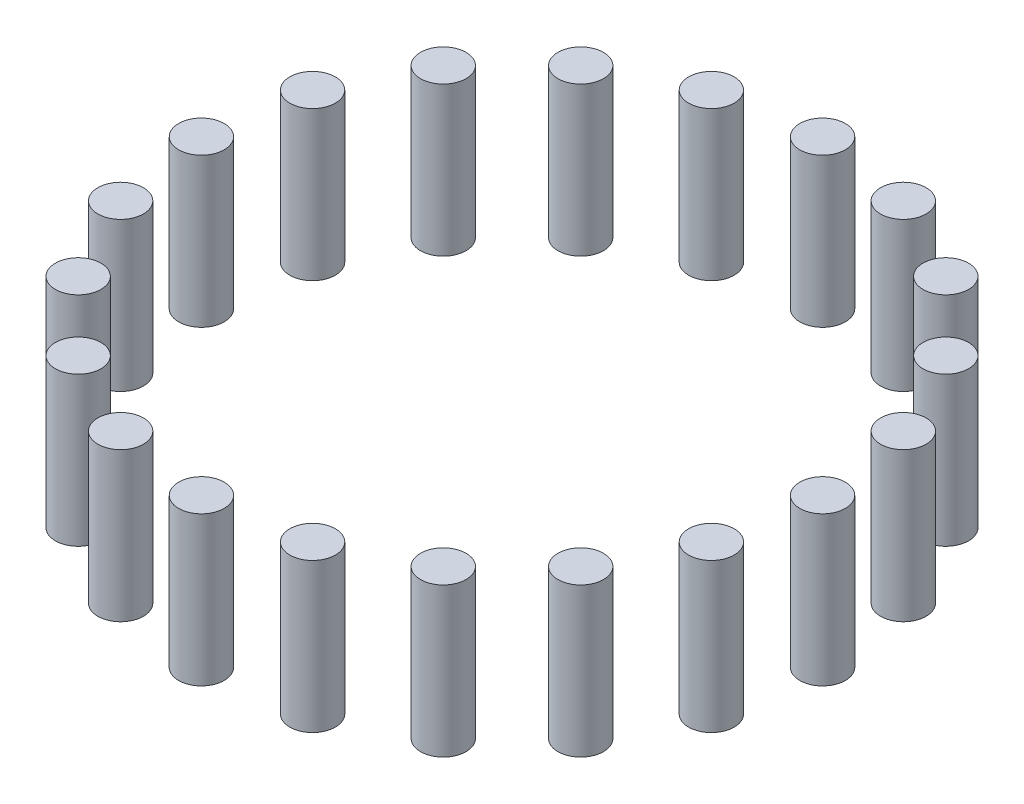
from build123d import *

# Parameters (mm, degrees)
SKETCH1_R              = 5.5
BOSS_EXTRUDE1_DEPTH    = 36
BOSS_EXTRUDE1_2_DEPTH  = 36
BOSS_EXTRUDE1_3_DEPTH  = 36
BOSS_EXTRUDE1_4_DEPTH  = 36
BOSS_EXTRUDE1_5_DEPTH  = 36
BOSS_EXTRUDE1_6_DEPTH  = 36
BOSS_EXTRUDE1_7_DEPTH  = 36
BOSS_EXTRUDE1_8_DEPTH  = 36
BOSS_EXTRUDE1_9_DEPTH  = 36
BOSS_EXTRUDE1_10_DEPTH = 36
BOSS_EXTRUDE1_11_DEPTH = 36
BOSS_EXTRUDE1_12_DEPTH = 36
BOSS_EXTRUDE1_13_DEPTH = 36
BOSS_EXTRUDE1_14_DEPTH = 36
BOSS_EXTRUDE1_15_DEPTH = 36
BOSS_EXTRUDE1_16_DEPTH = 36
BOSS_EXTRUDE1_17_DEPTH = 36
BOSS_EXTRUDE1_18_DEPTH = 36
BOSS_EXTRUDE1_19_DEPTH = 36
BOSS_EXTRUDE1_20_DEPTH = 36


with BuildPart() as part:
    # Sketch1 → Boss-Extrude1 (new body)
    with BuildSketch(Plane(origin=(0, 0, 0), x_dir=(1, 0, 0), z_dir=(0, 1, 0))):
        with Locations((75, 0)):
            Circle(SKETCH1_R)
    extrude(amount=BOSS_EXTRUDE1_DEPTH)


with BuildPart() as body_2:
    # Sketch1 → Boss-Extrude1 2 (new body)
    with BuildSketch(Plane(origin=(0, 0, 0), x_dir=(1, 0, 0), z_dir=(0, 1, 0))):
        with Locations((71.329238722, -23.176274578)):
            Circle(SKETCH1_R)
    extrude(amount=BOSS_EXTRUDE1_2_DEPTH)


with BuildPart() as body_3:
    # Sketch1 → Boss-Extrude1 3 (new body)
    with BuildSketch(Plane(origin=(0, 0, 0), x_dir=(1, 0, 0), z_dir=(0, 1, 0))):
        with Locations((60.676274578, -44.083893922)):
            Circle(SKETCH1_R)
    extrude(amount=BOSS_EXTRUDE1_3_DEPTH)


with BuildPart() as body_4:
    # Sketch1 → Boss-Extrude1 4 (new body)
    with BuildSketch(Plane(origin=(0, 0, 0), x_dir=(1, 0, 0), z_dir=(0, 1, 0))):
        with Locations((44.083893922, -60.676274578)):
            Circle(SKETCH1_R)
    extrude(amount=BOSS_EXTRUDE1_4_DEPTH)


with BuildPart() as body_5:
    # Sketch1 → Boss-Extrude1 5 (new body)
    with BuildSketch(Plane(origin=(0, 0, 0), x_dir=(1, 0, 0), z_dir=(0, 1, 0))):
        with Locations((23.176274578, -71.329238722)):
            Circle(SKETCH1_R)
    extrude(amount=BOSS_EXTRUDE1_5_DEPTH)


with BuildPart() as body_6:
    # Sketch1 → Boss-Extrude1 6 (new body)
    with BuildSketch(Plane(origin=(0, 0, 0), x_dir=(1, 0, 0), z_dir=(0, 1, 0))):
        with Locations((0, -75)):
            Circle(SKETCH1_R)
    extrude(amount=BOSS_EXTRUDE1_6_DEPTH)


with BuildPart() as body_7:
    # Sketch1 → Boss-Extrude1 7 (new body)
    with BuildSketch(Plane(origin=(0, 0, 0), x_dir=(1, 0, 0), z_dir=(0, 1, 0))):
        with Locations((-23.176274578, -71.329238722)):
            Circle(SKETCH1_R)
    extrude(amount=BOSS_EXTRUDE1_7_DEPTH)


with BuildPart() as body_8:
    # Sketch1 → Boss-Extrude1 8 (new body)
    with BuildSketch(Plane(origin=(0, 0, 0), x_dir=(1, 0, 0), z_dir=(0, 1, 0))):
        with Locations((-44.083893922, -60.676274578)):
            Circle(SKETCH1_R)
    extrude(amount=BOSS_EXTRUDE1_8_DEPTH)


with BuildPart() as body_9:
    # Sketch1 → Boss-Extrude1 9 (new body)
    with BuildSketch(Plane(origin=(0, 0, 0), x_dir=(1, 0, 0), z_dir=(0, 1, 0))):
        with Locations((-60.676274578, -44.083893922)):
            Circle(SKETCH1_R)
    extrude(amount=BOSS_EXTRUDE1_9_DEPTH)


with BuildPart() as body_10:
    # Sketch1 → Boss-Extrude1 10 (new body)
    with BuildSketch(Plane(origin=(0, 0, 0), x_dir=(1, 0, 0), z_dir=(0, 1, 0))):
        with Locations((-71.329238722, -23.176274578)):
            Circle(SKETCH1_R)
    extrude(amount=BOSS_EXTRUDE1_10_DEPTH)


with BuildPart() as body_11:
    # Sketch1 → Boss-Extrude1 11 (new body)
    with BuildSketch(Plane(origin=(0, 0, 0), x_dir=(1, 0, 0), z_dir=(0, 1, 0))):
        with Locations((-75, 0)):
            Circle(SKETCH1_R)
    extrude(amount=BOSS_EXTRUDE1_11_DEPTH)


with BuildPart() as body_12:
    # Sketch1 → Boss-Extrude1 12 (new body)
    with BuildSketch(Plane(origin=(0, 0, 0), x_dir=(1, 0, 0), z_dir=(0, 1, 0))):
        with Locations((-71.329238722, 23.176274578)):
            Circle(SKETCH1_R)
    extrude(amount=BOSS_EXTRUDE1_12_DEPTH)


with BuildPart() as body_13:
    # Sketch1 → Boss-Extrude1 13 (new body)
    with BuildSketch(Plane(origin=(0, 0, 0), x_dir=(1, 0, 0), z_dir=(0, 1, 0))):
        with Locations((-60.676274578, 44.083893922)):
            Circle(SKETCH1_R)
    extrude(amount=BOSS_EXTRUDE1_13_DEPTH)


with BuildPart() as body_14:
    # Sketch1 → Boss-Extrude1 14 (new body)
    with BuildSketch(Plane(origin=(0, 0, 0), x_dir=(1, 0, 0), z_dir=(0, 1, 0))):
        with Locations((-44.083893922, 60.676274578)):
            Circle(SKETCH1_R)
    extrude(amount=BOSS_EXTRUDE1_14_DEPTH)


with BuildPart() as body_15:
    # Sketch1 → Boss-Extrude1 15 (new body)
    with BuildSketch(Plane(origin=(0, 0, 0), x_dir=(1, 0, 0), z_dir=(0, 1, 0))):
        with Locations((-23.176274578, 71.329238722)):
            Circle(SKETCH1_R)
    extrude(amount=BOSS_EXTRUDE1_15_DEPTH)


with BuildPart() as body_16:
    # Sketch1 → Boss-Extrude1 16 (new body)
    with BuildSketch(Plane(origin=(0, 0, 0), x_dir=(1, 0, 0), z_dir=(0, 1, 0))):
        with Locations((0, 75)):
            Circle(SKETCH1_R)
    extrude(amount=BOSS_EXTRUDE1_16_DEPTH)


with BuildPart() as body_17:
    # Sketch1 → Boss-Extrude1 17 (new body)
    with BuildSketch(Plane(origin=(0, 0, 0), x_dir=(1, 0, 0), z_dir=(0, 1, 0))):
        with Locations((23.176274578, 71.329238722)):
            Circle(SKETCH1_R)
    extrude(amount=BOSS_EXTRUDE1_17_DEPTH)


with BuildPart() as body_18:
    # Sketch1 → Boss-Extrude1 18 (new body)
    with BuildSketch(Plane(origin=(0, 0, 0), x_dir=(1, 0, 0), z_dir=(0, 1, 0))):
        with Locations((44.083893922, 60.676274578)):
            Circle(SKETCH1_R)
    extrude(amount=BOSS_EXTRUDE1_18_DEPTH)


with BuildPart() as body_19:
    # Sketch1 → Boss-Extrude1 19 (new body)
    with BuildSketch(Plane(origin=(0, 0, 0), x_dir=(1, 0, 0), z_dir=(0, 1, 0))):
        with Locations((60.676274578, 44.083893922)):
            Circle(SKETCH1_R)
    extrude(amount=BOSS_EXTRUDE1_19_DEPTH)


with BuildPart() as body_20:
    # Sketch1 → Boss-Extrude1 20 (new body)
    with BuildSketch(Plane(origin=(0, 0, 0), x_dir=(1, 0, 0), z_dir=(0, 1, 0))):
        with Locations((71.329238722, 23.176274578)):
            Circle(SKETCH1_R)
    extrude(amount=BOSS_EXTRUDE1_20_DEPTH)


solid = Compound([part.part, body_2.part, body_3.part, body_4.part, body_5.part, body_6.part, body_7.part, body_8.part, body_9.part, body_10.part, body_11.part, body_12.part, body_13.part, body_14.part, body_15.part, body_16.part, body_17.part, body_18.part, body_19.part, body_20.part])
